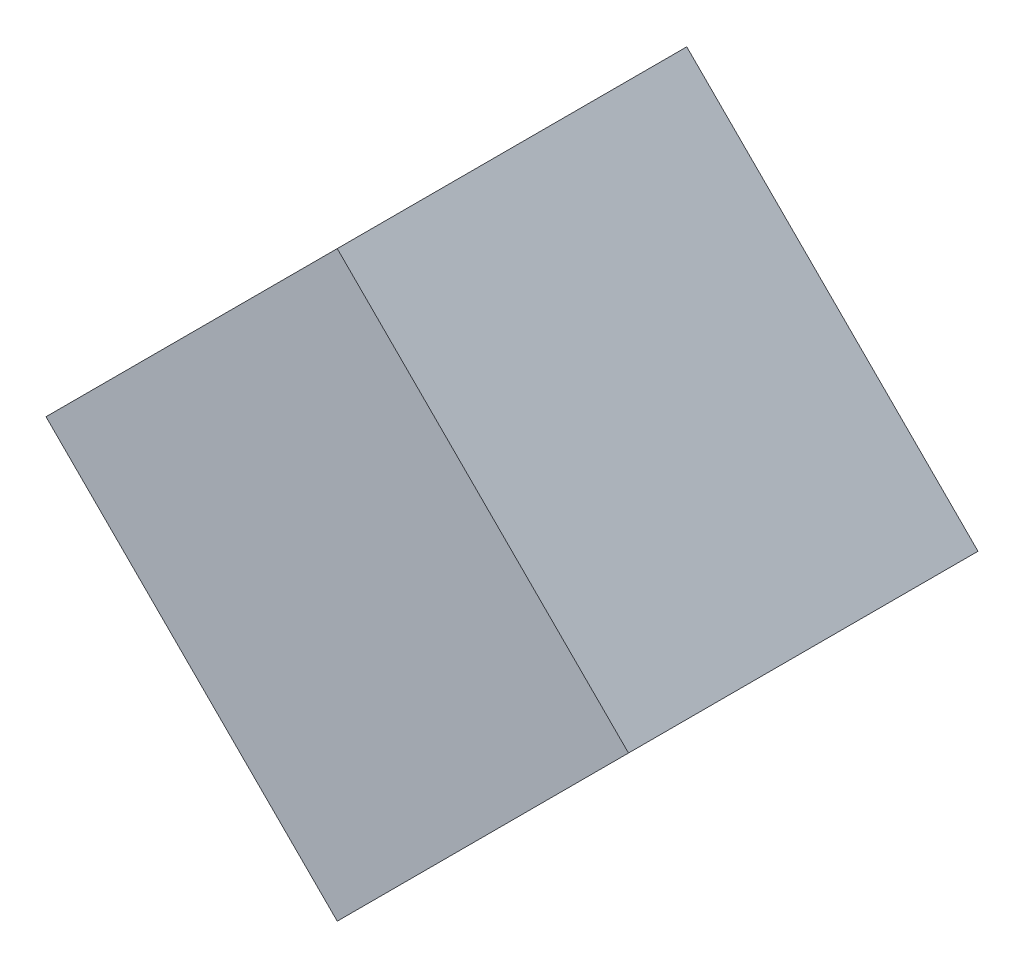
from build123d import *

# Parameters (mm, degrees)
ESTRUSIONE_ESTRUSIONE1_DEPTH = 30


with BuildPart() as part:
    # Schizzo1 → Estrusione-Estrusione1 (new body)
    with BuildSketch(Plane.XY):
        Polygon((25, 0), (0, 25), (-25, 0), (0, -25), align=None)
    extrude(amount=ESTRUSIONE_ESTRUSIONE1_DEPTH)


solid = part.part
